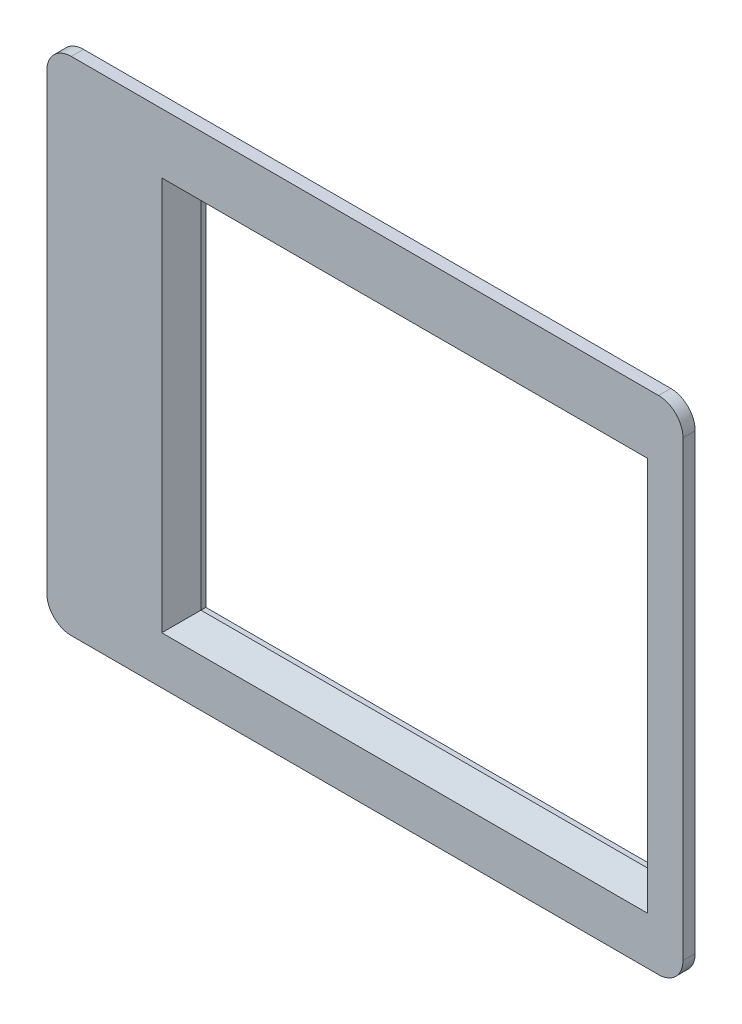
from build123d import *

# Parameters (mm, degrees)
SKETCH_1_W      = 52
SKETCH_1_H      = 41
SKETCH_1_W_2    = 46
SKETCH_1_H_2    = 35
EXTRUDE_1_DEPTH = 1
SKETCH_1_3_W    = 46
SKETCH_1_3_H    = 35
SKETCH_1_3_W_2  = 36.5
SKETCH_1_3_H_2  = 29
EXTRUDE_2_DEPTH = 2
FILLET_2_R      = 2
CHAMFER_1_SIZE  = 1.6


with BuildPart() as part:
    # Эскиз1 → Бобышка-Вытянуть1 (new body)
    with BuildSketch(Plane.XY):
        with Locations((23, 17.5)):
            Rectangle(SKETCH_1_W, SKETCH_1_H)
        with Locations((23, 17.5)):
            Rectangle(SKETCH_1_W_2, SKETCH_1_H_2, mode=Mode.SUBTRACT)
    extrude(amount=-EXTRUDE_1_DEPTH)

    # Эскиз1<3> → Бобышка-Вытянуть2 (add)
    with BuildSketch(Plane.XY):
        with Locations((23, 17.5)):
            Rectangle(SKETCH_1_3_W, SKETCH_1_3_H)
        with Locations((26.25, 17)):
            Rectangle(SKETCH_1_3_W_2, SKETCH_1_3_H_2, mode=Mode.SUBTRACT)
    extrude(amount=-EXTRUDE_2_DEPTH)

    # Скругление2
    fillet_2_edges = [part.edges().sort_by_distance(p)[0] for p in [
        (-3, -3, -0.5),
        (0, 0, -1.5),
        (49, -3, -0.5),
        (46, 0, -1.5),
        (49, 38, -0.5),
        (46, 35, -1.5),
        (-3, 38, -0.5),
        (0, 35, -1.5),
    ]]
    fillet(fillet_2_edges, radius=FILLET_2_R)

    # Фаска1
    chamfer_1_edges = [part.edges().sort_by_distance(p)[0] for p in [
        (26.25, 2.5, 0),
        (44.5, 17, 0),
        (8, 17, 0),
        (26.25, 31.5, 0),
    ]]
    chamfer(chamfer_1_edges, length=CHAMFER_1_SIZE)


solid = part.part
